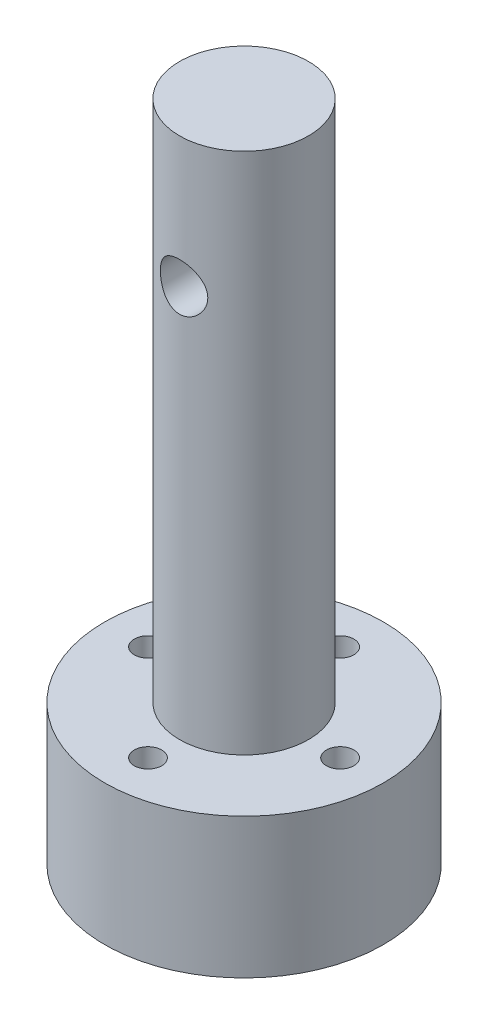
from build123d import *

# Parameters (mm, degrees)
SKETCH1_R               = 10.16
SKETCH1_R_2             = 1.000000032
BOSS_EXTRUDE1_DEPTH     = 19.05
SKETCH2_R               = 4.699
BOSS_EXTRUDE2_DEPTH     = 38.1
SKETCH4_R               = 10.16
CUT_EXTRUDE2_DEPTH      = 8.842000096
CUT_EXTRUDE3_START      = 8.842
SKETCH3_R               = 3.429
CUT_EXTRUDE3_DEPTH      = 3.175
SKETCH5_R               = 1.726999975
CUT_EXTRUDE4_DEPTH      = 11.16
CUT_EXTRUDE4_DEPTH_BACK = 11.16


with BuildPart() as part:
    # Sketch1 → Boss-Extrude1 (new body)
    with BuildSketch(Plane(origin=(0, 0, 0), x_dir=(1, 0, 0), z_dir=(0, 1, 0))):
        Circle(SKETCH1_R)
        with Locations((6.99999997, 0)):
            Circle(SKETCH1_R_2, mode=Mode.SUBTRACT)
        with Locations((0, -6.99999997)):
            Circle(SKETCH1_R_2, mode=Mode.SUBTRACT)
        with Locations((-6.99999997, 0)):
            Circle(SKETCH1_R_2, mode=Mode.SUBTRACT)
        with Locations((0, 6.99999997)):
            Circle(SKETCH1_R_2, mode=Mode.SUBTRACT)
    extrude(amount=BOSS_EXTRUDE1_DEPTH)

    # Sketch2 → Boss-Extrude2 (add)
    with BuildSketch(Plane(origin=(0, 19.05, 0), x_dir=(1, 0, 0), z_dir=(0, 1, 0))):
        Circle(SKETCH2_R)
    extrude(amount=BOSS_EXTRUDE2_DEPTH)

    # Sketch4 → Cut-Extrude2 (cut)
    with BuildSketch(Plane.XZ):
        Circle(SKETCH4_R)
    extrude(amount=-CUT_EXTRUDE2_DEPTH, mode=Mode.SUBTRACT)

    # Sketch3 → Cut-Extrude3 (cut)
    with BuildSketch(Plane(origin=(0, 0, 0), x_dir=(1, 0, 0), z_dir=(0, 1, 0)).offset(CUT_EXTRUDE3_START)):
        Circle(SKETCH3_R)
    extrude(amount=CUT_EXTRUDE3_DEPTH, mode=Mode.SUBTRACT)

    # Sketch5 → Cut-Extrude4 (cut, two sides)
    with BuildSketch(Plane.XY) as cut_extrude4_sk:
        with Locations((0, 47.625)):
            Circle(SKETCH5_R)
    extrude(amount=CUT_EXTRUDE4_DEPTH, mode=Mode.SUBTRACT)
    extrude(cut_extrude4_sk.sketch, amount=-CUT_EXTRUDE4_DEPTH_BACK, mode=Mode.SUBTRACT)


solid = part.part
